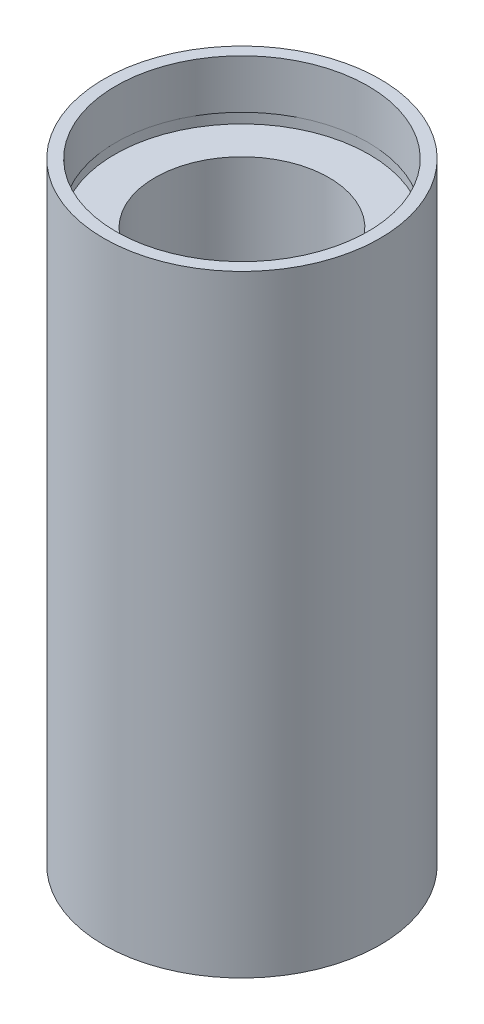
from build123d import *


with BuildPart() as part:
    # 草图1 → 旋转1 (revolve)
    with BuildSketch(Plane.XY, mode=Mode.PRIVATE) as revolve_1_sk:
        Polygon((11.1, 0), (11.1, 4.5), (11.7, 4.5), (11.7, 5.5), (8, 5.5), (8, 50.8), (11.7, 50.8), (11.7, 51.8), (11.6, 51.8), (11.6, 56.3), (12.7, 56.3), (12.7, 0), align=None)
    revolve(revolve_1_sk.sketch.rotate(Axis((0, 161.376166943, 0), (0, -1, 0)), 90), axis=Axis((0, 161.376166943, 0), (0, -1, 0)))  # turned: the seam where the file's is


solid = part.part
